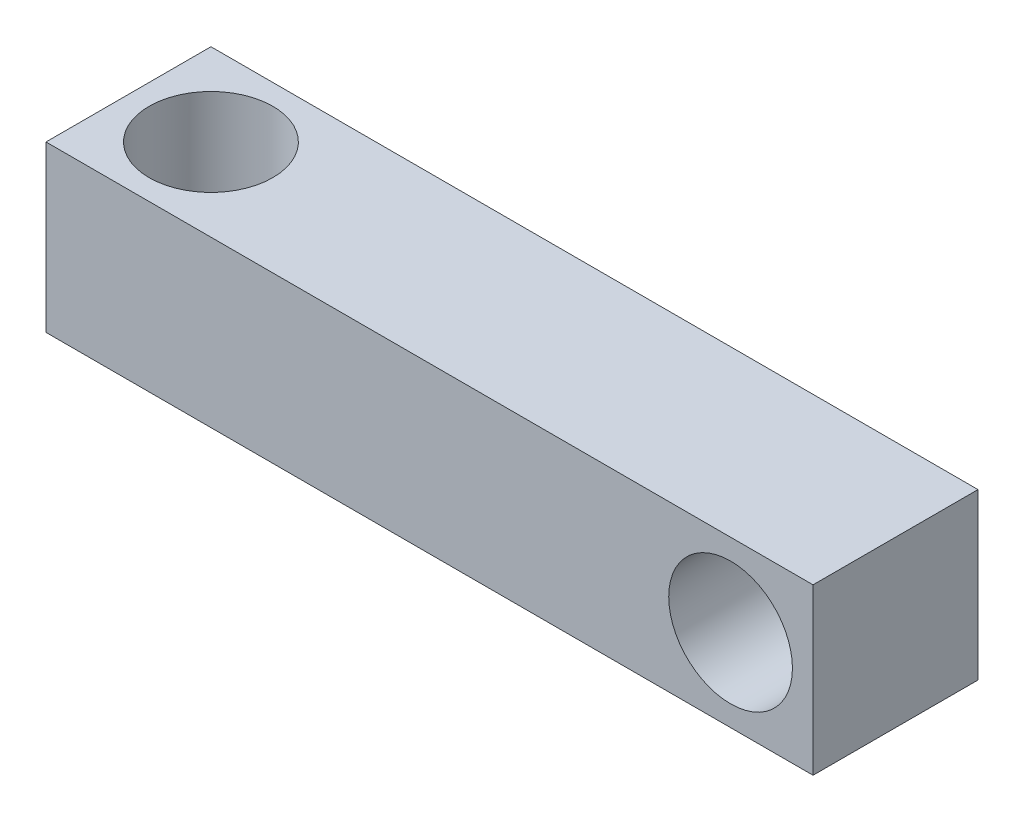
from build123d import *

# Parameters (mm, degrees)
SALIENTE_EXTRUIR1_DEPTH    = 10
CROQUIS2_R                 = 7.5
CORTAR_EXTRUIR1_DEPTH      = 1
CORTAR_EXTRUIR1_DEPTH_BACK = 21
CROQUIS3_R                 = 7.5
CORTAR_EXTRUIR2_DEPTH      = 1
CORTAR_EXTRUIR2_DEPTH_BACK = 21


with BuildPart() as part:
    # Croquis1 → Saliente-Extruir1 (new body, symmetric)
    with BuildSketch(Plane.XY):
        Polygon((0, 11.759082218), (46.5, 11.759082218), (46.5, -8.240917782), (-46.5, -8.240917782), (-46.5, 11.759082218), align=None)
    extrude(amount=SALIENTE_EXTRUIR1_DEPTH, both=True)

    # Croquis2 → Cortar-Extruir1 (cut, two sides)
    with BuildSketch(Plane.XY.offset(10)) as cortar_extruir1_sk:
        with Locations((36.5, 1.759082218)):
            Circle(CROQUIS2_R)
    extrude(amount=CORTAR_EXTRUIR1_DEPTH, mode=Mode.SUBTRACT)
    extrude(cortar_extruir1_sk.sketch, amount=-CORTAR_EXTRUIR1_DEPTH_BACK, mode=Mode.SUBTRACT)

    # Croquis3 → Cortar-Extruir2 (cut, two sides)
    with BuildSketch(Plane(origin=(0, 11.759082218, 0), x_dir=(1, 0, 0), z_dir=(0, 1, 0))) as cortar_extruir2_sk:
        with Locations((-36.5, 0)):
            Circle(CROQUIS3_R)
    extrude(amount=CORTAR_EXTRUIR2_DEPTH, mode=Mode.SUBTRACT)
    extrude(cortar_extruir2_sk.sketch, amount=-CORTAR_EXTRUIR2_DEPTH_BACK, mode=Mode.SUBTRACT)


solid = part.part
